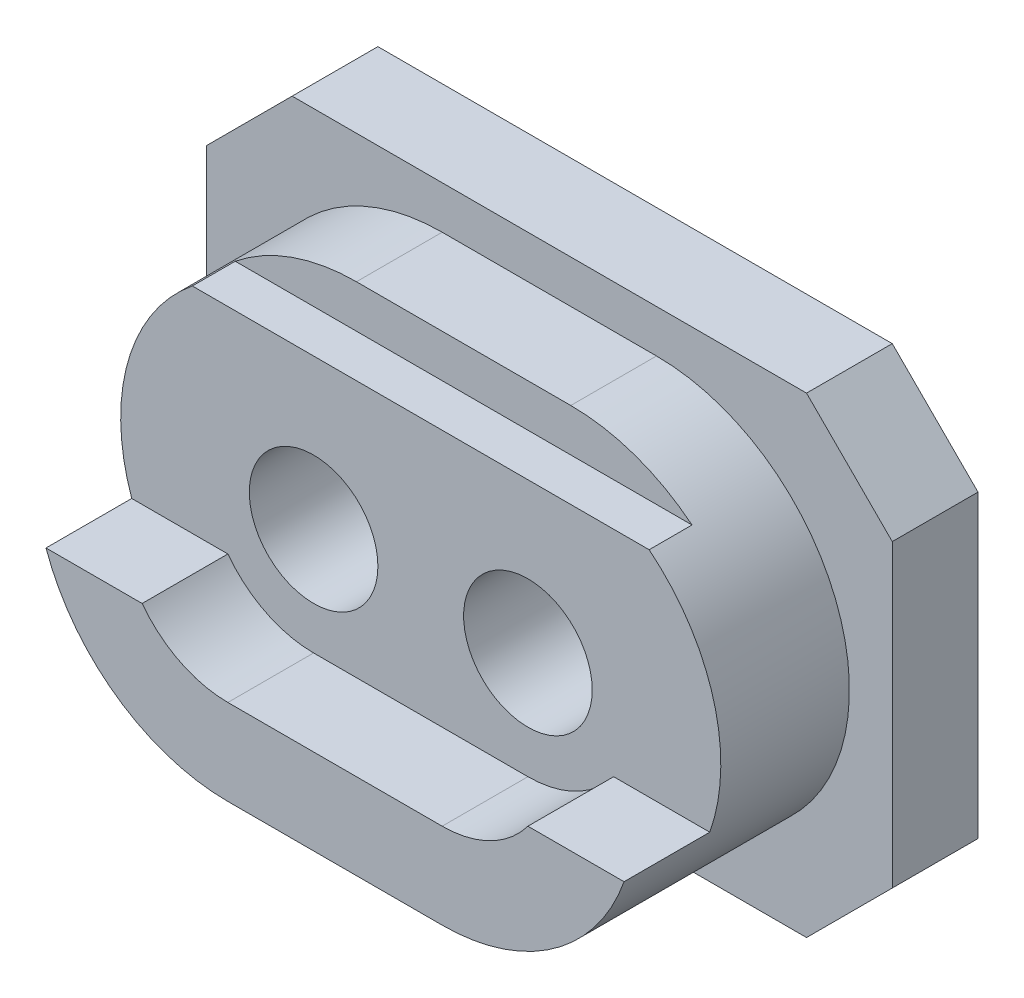
from build123d import *

# Parameters (mm, degrees)
SKETCH1_R           = 1.5
BOSS_EXTRUDE1_DEPTH = 2
SKETCH2_R           = 1.5
BOSS_EXTRUDE2_DEPTH = 5
CUT_EXTRUDE1_DEPTH  = 2
SKETCH5_W           = 3
SKETCH5_H           = 1
CUT_EXTRUDE2_DEPTH  = 22


with BuildPart() as part:
    # Sketch1 → Boss-Extrude1 (new body)
    with BuildSketch(Plane.XY):
        Polygon((-8, 3.5), (-6, 5.5), (6, 5.5), (8, 3.5), (8, -3.5), (6, -5.5), (-6, -5.5), (-8, -3.5), align=None)
        with Locations((-2.5, 0)):
            Circle(SKETCH1_R, mode=Mode.SUBTRACT)
        with Locations((2.5, 0)):
            Circle(SKETCH1_R, mode=Mode.SUBTRACT)
    extrude(amount=BOSS_EXTRUDE1_DEPTH)

    # Sketch2 → Boss-Extrude2 (add)
    with BuildSketch(Plane.XY.offset(2)):
        with BuildLine():
            Line((-2.5, 4.5), (2.5, 4.5))
            ThreePointArc((2.5, 4.5), (7, 0), (2.5, -4.5))
            Line((2.5, -4.5), (-2.5, -4.5))
            ThreePointArc((-2.5, -4.5), (-7, 0), (-2.5, 4.5))
        make_face()
        with Locations((-2.5, 0)):
            Circle(SKETCH2_R, mode=Mode.SUBTRACT)
        with Locations((2.5, 0)):
            Circle(SKETCH2_R, mode=Mode.SUBTRACT)
    extrude(amount=BOSS_EXTRUDE2_DEPTH)

    # Sketch4 → Cut-Extrude1 (cut)
    with BuildSketch(Plane.XY.offset(7)):
        with BuildLine():
            Line((-2.5, -2.5), (2.5, -2.5))
            ThreePointArc((2.5, -2.5), (3.618033989, -2.236067977), (4.5, -1.5))
            Line((4.5, -1.5), (7.291771179, -1.5))
            Line((7.291771179, -1.5), (6.980260776, 3.5))
            Line((6.980260776, 3.5), (4.540127242, 3.5))
            Line((4.540127242, 3.5), (-4.895055756, 3.5))
            Line((-4.895055756, 3.5), (-6.610543574, 3.5))
            Line((-6.610543574, 3.5), (-7.482128219, -1.5))
            Line((-7.482128219, -1.5), (-4.5, -1.5))
            ThreePointArc((-4.5, -1.5), (-3.618033989, -2.236067977), (-2.5, -2.5))
        make_face()
    extrude(amount=-CUT_EXTRUDE1_DEPTH, mode=Mode.SUBTRACT)

    # Sketch5 → Cut-Extrude2 (cut)
    with BuildSketch(Plane.ZY.offset(8)):
        with Locations((5.5, 4)):
            Rectangle(SKETCH5_W, SKETCH5_H)
    extrude(amount=-CUT_EXTRUDE2_DEPTH, mode=Mode.SUBTRACT)


solid = part.part
